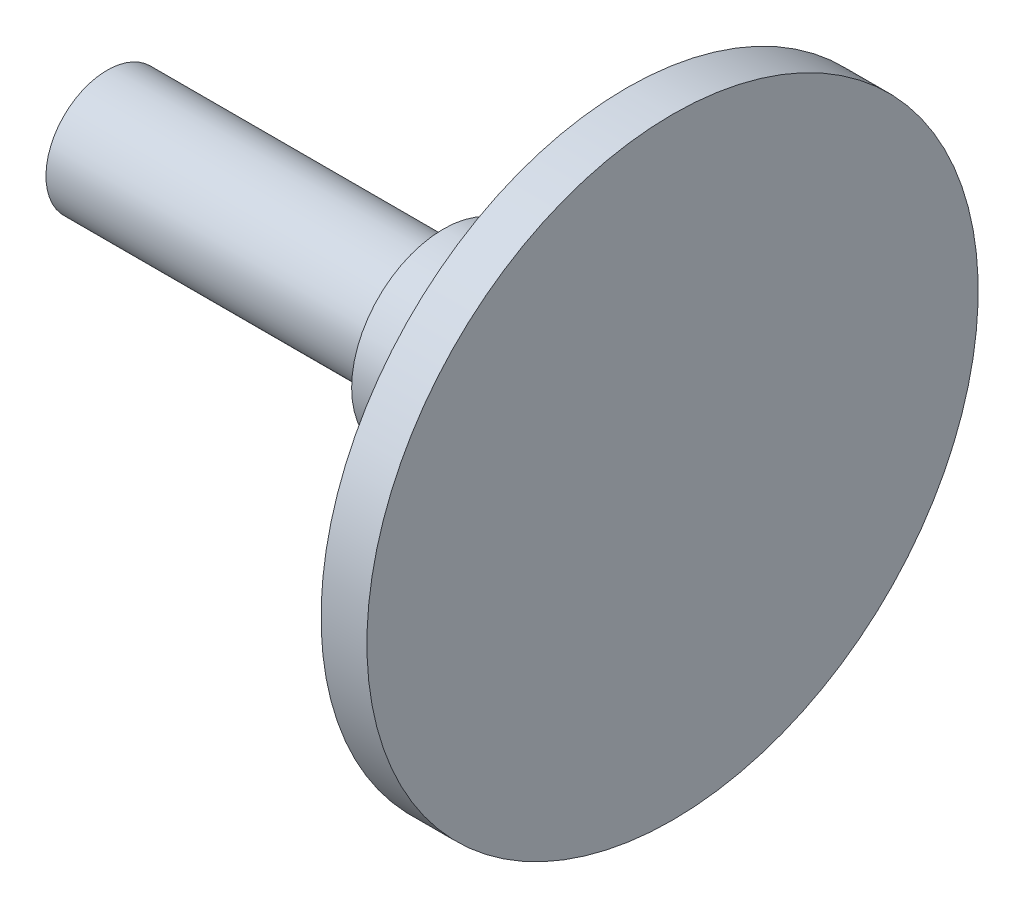
from build123d import *

# Parameters (mm, degrees)
SKETCH_2_R      = 3
EXTRUDE_1_DEPTH = 6


with BuildPart() as part:
    # 草图1 → 旋转1 (revolve)
    with BuildSketch(Plane.XY):
        Polygon((-18.5, 0), (-18.5, 2), (-1.5, 2), (-1.5, 10), (0, 10), (0, 2), (0, 0), align=None)
    revolve(axis=Axis((-18.5, 0, 0), (1, 0, 0)))

    # 草图2 → 凸台-拉伸1 (add)
    with BuildSketch(Plane.ZY.offset(1.5)):
        Circle(SKETCH_2_R)
    extrude(amount=EXTRUDE_1_DEPTH)


solid = part.part
